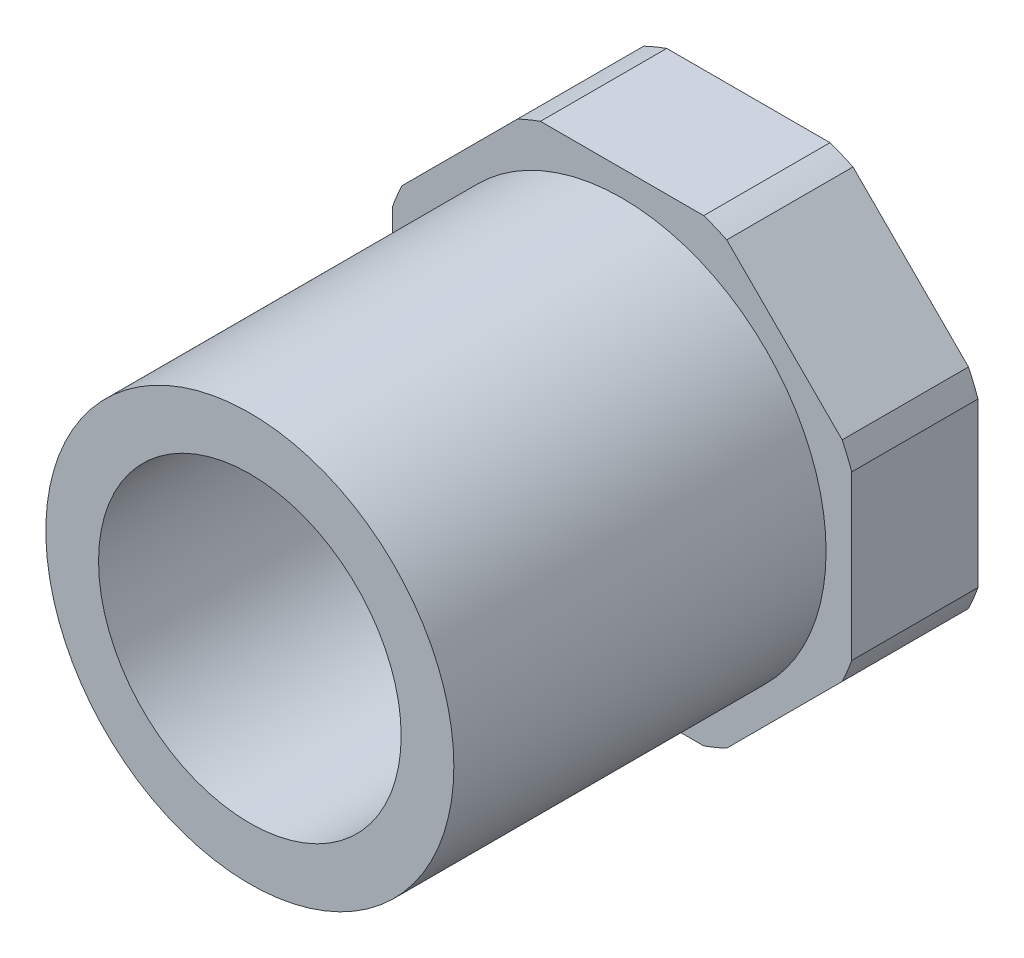
from build123d import *

# Parameters (mm, degrees)
SKETCH4_R           = 10.7188
BOSS_EXTRUDE1_DEPTH = 6.63575
SKETCH5_W           = 6.63575
SKETCH5_H           = 0.254


with BuildPart() as part:
    # Sketch3 → Revolve1 (revolve)
    with BuildSketch(Plane(origin=(0, 0, 0), x_dir=(0, 0, -1), z_dir=(1, 0, 0))):
        with BuildLine():
            Line((6.461125, 0), (13.096875, 0))
            Line((13.096875, 0), (13.096875, -10.7188))
            Line((13.096875, -10.7188), (-13.096875, -10.7188))
            Line((-13.096875, -10.7188), (-13.096875, -7.9502))
            Line((-13.096875, -7.9502), (4.873625, -7.9502))
            ThreePointArc((4.873625, -7.9502), (6.060370876, -4.053573618), (6.461125, 0))
        make_face()
    revolve(axis=Axis((0, 0, 13.096875), (0, 0, -1)))

    # Sketch4 → Boss-Extrude1 (add)
    with BuildSketch(Plane(origin=(0, 0, -13.096875), x_dir=(-1, 0, 0), z_dir=(0, 0, -1))):
        Polygon((4.99748663, 12.065), (-4.99748663, 12.065), (-12.065, 4.99748663), (-12.065, -4.99748663), (-4.99748663, -12.065), (4.99748663, -12.065), (12.065, -4.99748663), (12.065, 4.99748663), align=None)
        Circle(SKETCH4_R, mode=Mode.SUBTRACT)
    extrude(amount=-BOSS_EXTRUDE1_DEPTH)

    # Sketch5 → Cut-Revolve1 (revolve, cut)
    with BuildSketch(Plane(origin=(0, 0, 0), x_dir=(0, 0, -1), z_dir=(0.923879533, -0.382683432, 0))):
        with Locations((9.779, 12.932061897)):
            Rectangle(SKETCH5_W, SKETCH5_H)
    revolve(axis=Axis((0, 0, 13.096875), (0, 0, 1)), mode=Mode.SUBTRACT)


solid = part.part
